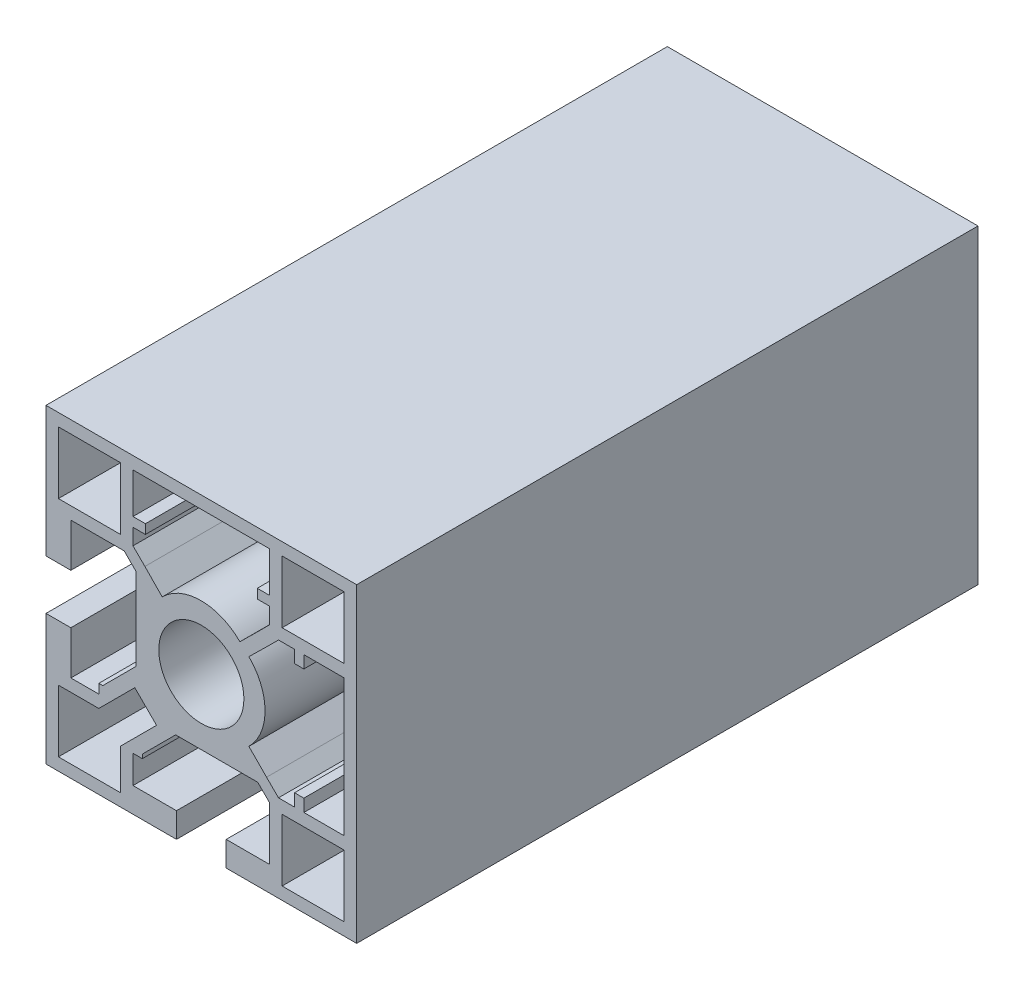
from build123d import *

# Parameters (mm, degrees)
SKETCH_A01_7_R     = 6.85
SKETCH_A01_7_W     = 10
SKETCH_A01_7_H     = 10
EXTRUDE1_DEPTH     = 100
CUT_EXTRUDE1_DEPTH = 101
CUT_EXTRUDE2_DEPTH = 101
CIRPATTERN2_COUNT  = 2
CIRPATTERN2_ANGLE  = 270
SKETCH3_W          = 2
SKETCH3_H          = 1.5
EXTRUDE3_DEPTH     = 100
SKETCH4_W          = 1.5
SKETCH4_H          = 2
EXTRUDE4_DEPTH     = 100


with BuildPart() as part:
    # Sketch A01-7 → Extrude1 (new body)
    with BuildSketch(Plane.XY):
        Polygon((-16.5, -11), (-16.5, -9.5), (-15.863959988, -9.5), (-10.5, -4.136038954), (-10.5, 9.085786), (-12.414214, 11), (-21, 11), (-21, 4), (-25, 4), (-25, 25), (25, 25), (25, -25), (4, -25), (4, -21), (11, -21), (11, -12.414214), (9.085786, -10.5), (-4.136039046, -10.5), (-9.5, -15.863962012), (-9.5, -16.5), (-11, -16.5), (-11, -21), (-4, -21), (-4, -25), (-25, -25), (-25, -4), (-21, -4), (-21, -11), align=None)
        Circle(SKETCH_A01_7_R, mode=Mode.SUBTRACT)
        Polygon((12.414213, -11), (10.500000477, -9.085787477), (10.500000477, 9.085786477), (12.414214, 11), (23, 11), (23, -11), align=None, mode=Mode.SUBTRACT)
        Polygon((11, 12.414213), (9.085787477, 10.500000477), (-9.085786477, 10.500000477), (-11, 12.414214), (-11, 23), (11, 23), align=None, mode=Mode.SUBTRACT)
        with Locations((-18, -18)):
            Rectangle(SKETCH_A01_7_W, SKETCH_A01_7_H, mode=Mode.SUBTRACT)
        with Locations((18, -18)):
            Rectangle(SKETCH_A01_7_W, SKETCH_A01_7_H, mode=Mode.SUBTRACT)
        with Locations((-18, 18)):
            Rectangle(SKETCH_A01_7_W, SKETCH_A01_7_H, mode=Mode.SUBTRACT)
        with Locations((18, 18)):
            Rectangle(SKETCH_A01_7_W, SKETCH_A01_7_H, mode=Mode.SUBTRACT)
    extrude(amount=-EXTRUDE1_DEPTH)

    # Sketch1 → Cut-Extrude1 (cut, through all)
    with BuildSketch(Plane.XY):
        Polygon((-16.5, -13), (-10.707726017, -7.207724875), (-7.207726017, -10.707724185), (-13, -16.49999931), align=None)
    extrude(amount=-CUT_EXTRUDE1_DEPTH, mode=Mode.SUBTRACT)

    # Sketch2 → Cut-Extrude2 (cut, through all)
    with BuildSketch(Plane.XY):
        with BuildLine():
            Line((-9.085786477, 10.500000477), (-6.294899419, 7.650918733))
            ThreePointArc((-6.294899419, 7.650918733), (-0.042574105, 10.257977016), (6.209751208, 7.650918733))
            Line((6.209751208, 7.650918733), (9.085787477, 10.500000477))
            Line((9.085787477, 10.500000477), (-9.085786477, 10.500000477))
        make_face()
    cut_extrude2 = extrude(amount=-CUT_EXTRUDE2_DEPTH, mode=Mode.SUBTRACT)

    # CirPattern2: Cut-Extrude2 ×2 about axis
    cirpattern2_axis = Axis((0, 0, 0), (0, 0, 1))
    for i in range(1, CIRPATTERN2_COUNT):
        add(cut_extrude2.rotate(cirpattern2_axis, i * CIRPATTERN2_ANGLE / (CIRPATTERN2_COUNT - 1)), mode=Mode.SUBTRACT)

    # Sketch3 → Extrude3 (add, through all)
    with BuildSketch(Plane.XY):
        with Locations((-10, 15.75)):
            Rectangle(SKETCH3_W, SKETCH3_H)
        with Locations((10, 15.75)):
            Rectangle(SKETCH3_W, SKETCH3_H)
    extrude(amount=-EXTRUDE3_DEPTH)

    # Sketch4 → Extrude4 (add, through all)
    with BuildSketch(Plane.XY):
        with Locations((15.75, 10)):
            Rectangle(SKETCH4_W, SKETCH4_H)
        with Locations((15.75, -10)):
            Rectangle(SKETCH4_W, SKETCH4_H)
    extrude(amount=-EXTRUDE4_DEPTH)


solid = part.part
